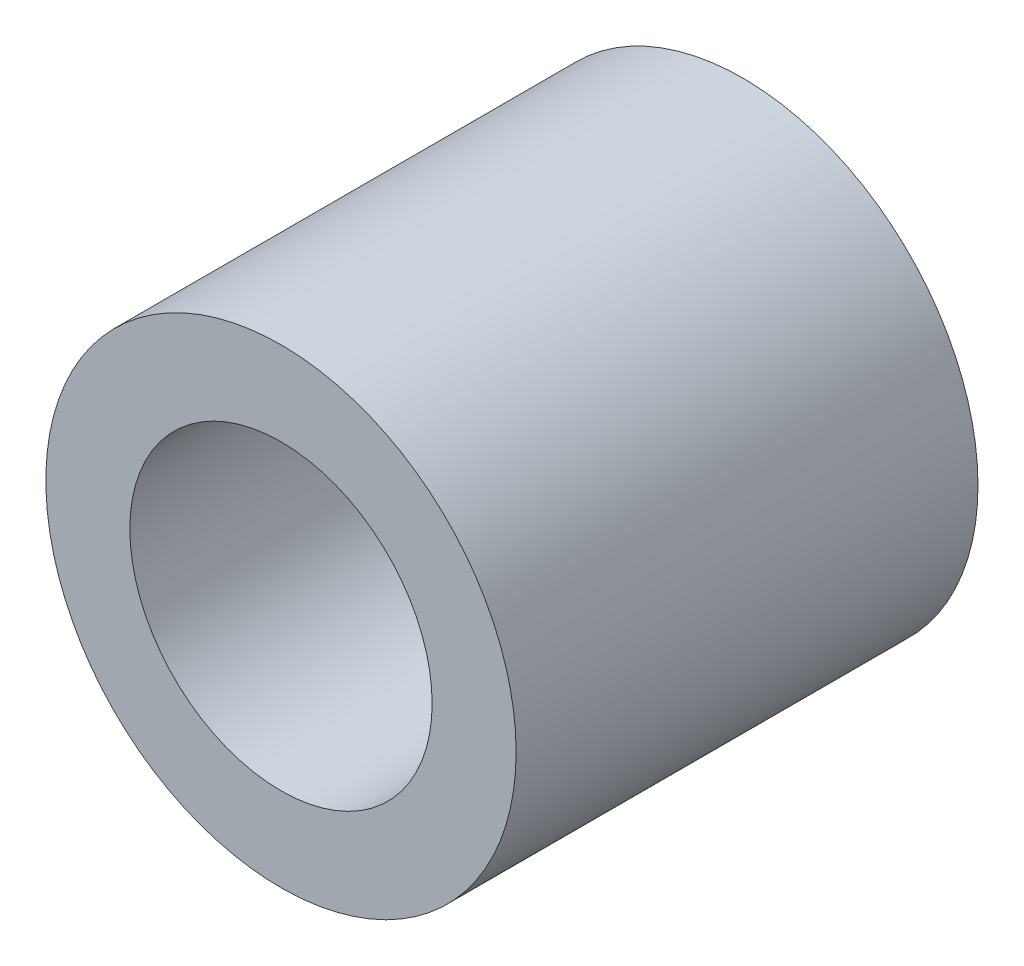
from build123d import *

# Parameters (mm, degrees)
SKETCH1_R           = 2.8
SKETCH1_R_2         = 1.8
BOSS_EXTRUDE1_DEPTH = 5.5


with BuildPart() as part:
    # Sketch1 → Boss-Extrude1 (new body)
    with BuildSketch(Plane.XY):
        Circle(SKETCH1_R)
        Circle(SKETCH1_R_2, mode=Mode.SUBTRACT)
    extrude(amount=BOSS_EXTRUDE1_DEPTH)


solid = part.part
